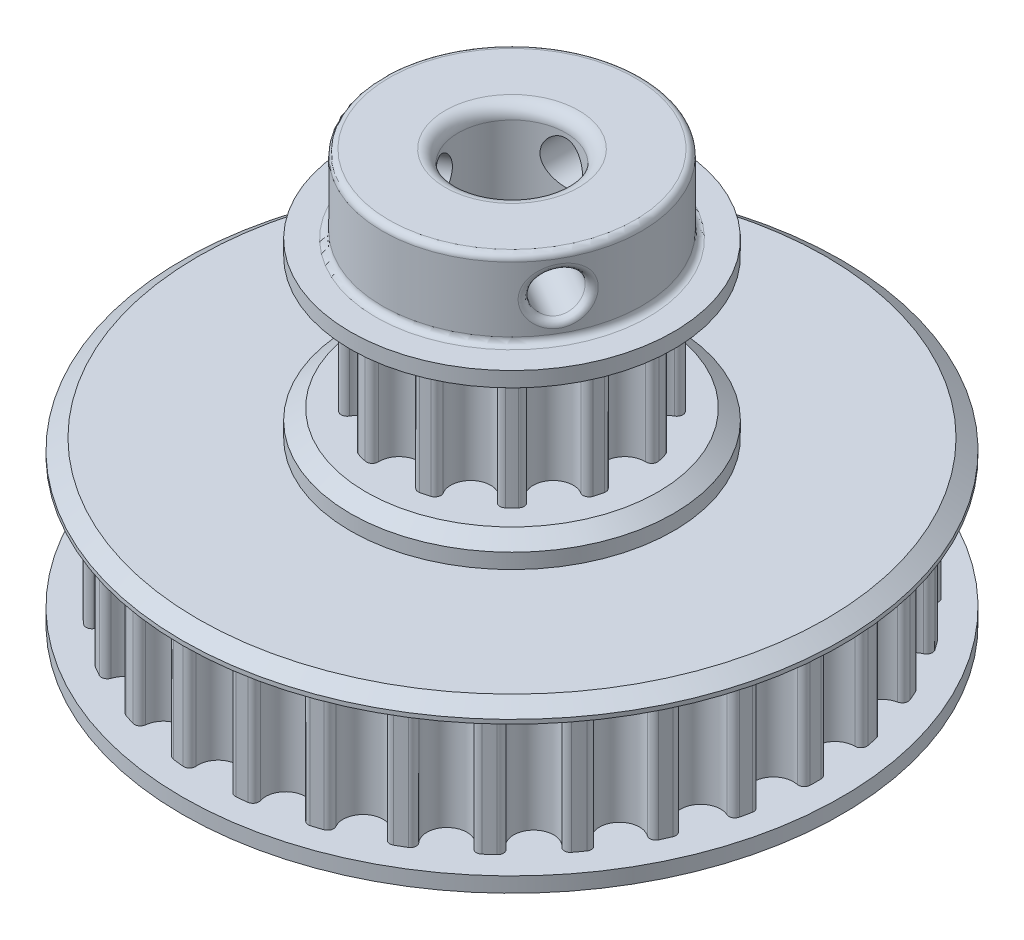
from build123d import *

# Parameters (mm, degrees)
BOSS_EXTRU_1_DEPTH           = 9.3
R_P_TITION_CIRCULAIRE1_COUNT = 12
ESQUISSE2_R                  = 12.462209394
BOSS_EXTRU_2_DEPTH           = 2
ESQUISSE4_R                  = 10
BOSS_EXTRU_3_DEPTH           = 6
ESQUISSE5_R                  = 1.65
ENL_V_MAT_EXTRU_2_DEPTH      = 13.462209394
R_P_TITION_CIRCULAIRE2_COUNT = 3
ESQUISSE10_R                 = 12.462209394
BOSS_EXTRU_6_DEPTH           = 2
BOSS_EXTRU_4_DEPTH           = 9.3
R_P_TITION_CIRCULAIRE3_COUNT = 30
ESQUISSE9_R                  = 25.4290252
BOSS_EXTRU_5_DEPTH           = 2
CHANFREIN1_SIZE              = 1.2
CHANFREIN1_SIZE2             = 0.840249046
CHANFREIN1_PART_2_SIZE       = 1.2
CHANFREIN1_PART_2_SIZE2      = 0.840249046
CHANFREIN1_PART_3_SIZE       = 1.2
CHANFREIN1_PART_3_SIZE2      = 0.840249046
CHANFREIN1_PART_4_SIZE       = 1.2
CHANFREIN1_PART_4_SIZE2      = 0.840249046
CHANFREIN1_PART_5_SIZE       = 1.2
CHANFREIN1_PART_5_SIZE2      = 0.840249046
ESQUISSE3_R                  = 4.15
ENL_V_MAT_EXTRU_3_DEPTH      = 33.6
CONG_2_R                     = 0.5
CONG_3_R                     = 1


with BuildPart() as part:
    # Esquisse1 → Boss.-Extru.1 (new body)
    with BuildSketch(Plane(origin=(0, 0, 0), x_dir=(1, 0, 0), z_dir=(0, 1, 0))):
        with BuildLine():
            Line((0, 0), (-2.449, 9.139792428))
            ThreePointArc((-2.449, 9.139792428), (-2.275575871, 9.184506578), (-2.101336519, 9.225930384))
            ThreePointArc((-2.101336519, 9.225930384), (-1.70739936, 9.132025425), (-1.541940008, 8.762393406))
            ThreePointArc((-1.541940008, 8.762393406), (0, 7.162209394), (1.541940008, 8.762393406))
            ThreePointArc((1.541940008, 8.762393406), (1.70739936, 9.132025425), (2.101336519, 9.225930384))
            ThreePointArc((2.101336519, 9.225930384), (2.275575871, 9.184506578), (2.449, 9.139792428))
            Line((2.449, 9.139792428), (0, 0))
        make_face()
    boss_extru_1 = extrude(amount=BOSS_EXTRU_1_DEPTH)

    # Répétition circulaire1: Boss.-Extru.1 ×12 about axis
    r_p_tition_circulaire1_axis = Axis((0, 0, 0), (0, 1, 0))
    for i in range(1, R_P_TITION_CIRCULAIRE1_COUNT):
        add(boss_extru_1.rotate(r_p_tition_circulaire1_axis, i * 360 / R_P_TITION_CIRCULAIRE1_COUNT))

    # Esquisse2 → Boss.-Extru.2 (add)
    with BuildSketch(Plane(origin=(0, 9.3, 0), x_dir=(1, 0, 0), z_dir=(0, 1, 0))):
        Circle(ESQUISSE2_R)
    boss_extru_2 = extrude(amount=BOSS_EXTRU_2_DEPTH)

    # Symétrie1: Boss.-Extru.2 across plane
    add(boss_extru_2.mirror(Plane(origin=(0, 4.65, 0), x_dir=(0, 0, 1), z_dir=(0, -1, 0))))

    # Esquisse4 → Boss.-Extru.3 (add)
    with BuildSketch(Plane(origin=(0, 11.3, 0), x_dir=(1, 0, 0), z_dir=(0, 1, 0))):
        Circle(ESQUISSE4_R)
    extrude(amount=BOSS_EXTRU_3_DEPTH)

    # Esquisse5 → Enlèv. mat.-Extru.2 (cut, through all)
    with BuildSketch(Plane.XY):
        with Locations((0, 14.3)):
            Circle(ESQUISSE5_R)
    enl_v_mat_extru_2 = extrude(amount=-ENL_V_MAT_EXTRU_2_DEPTH, mode=Mode.SUBTRACT)

    # Répétition circulaire2: Enlèv. mat.-Extru.2 ×3 about axis
    r_p_tition_circulaire2_axis = Axis((0, 17.3, 0), (0, -1, 0))
    for i in range(1, R_P_TITION_CIRCULAIRE2_COUNT):
        add(enl_v_mat_extru_2.rotate(r_p_tition_circulaire2_axis, i * 360 / R_P_TITION_CIRCULAIRE2_COUNT), mode=Mode.SUBTRACT)

    # Esquisse10 → Boss.-Extru.6 (add)
    with BuildSketch(Plane.XZ.offset(2)):
        Circle(ESQUISSE10_R)
    extrude(amount=BOSS_EXTRU_6_DEPTH)

    # Esquisse7 → Boss.-Extru.4 (add)
    with BuildSketch(Plane(origin=(0, -4, 0), x_dir=(1, 0, 0), z_dir=(0, 1, 0))):
        with BuildLine():
            Line((0, 0), (-2.449, 23.300678548))
            ThreePointArc((-2.449, 23.300678548), (-2.23925905, 23.321769674), (-2.029336827, 23.340972856))
            ThreePointArc((-2.029336827, 23.340972856), (-1.662628217, 23.205334027), (-1.534260602, 22.83601729))
            ThreePointArc((-1.534260602, 22.83601729), (0, 21.1290252), (1.534260602, 22.83601729))
            ThreePointArc((1.534260602, 22.83601729), (1.662628217, 23.205334027), (2.029336827, 23.340972856))
            ThreePointArc((2.029336827, 23.340972856), (2.23925905, 23.321769674), (2.449, 23.300678548))
            Line((2.449, 23.300678548), (0, 0))
        make_face()
    boss_extru_4 = extrude(amount=-BOSS_EXTRU_4_DEPTH)

    # Répétition circulaire3: Boss.-Extru.4 ×30 about axis
    r_p_tition_circulaire3_axis = Axis((0, 0, 0), (0, 1, 0))
    for i in range(1, R_P_TITION_CIRCULAIRE3_COUNT):
        add(boss_extru_4.rotate(r_p_tition_circulaire3_axis, i * 360 / R_P_TITION_CIRCULAIRE3_COUNT))

    # Esquisse9 → Boss.-Extru.5 (add)
    with BuildSketch(Plane(origin=(0, -4, 0), x_dir=(1, 0, 0), z_dir=(0, 1, 0))):
        Circle(ESQUISSE9_R)
    boss_extru_5 = extrude(amount=BOSS_EXTRU_5_DEPTH)

    # Symétrie2: Boss.-Extru.5 across plane
    add(boss_extru_5.mirror(Plane.ZX.offset(-8.65)))

    # Chanfrein1
    chanfrein1_edges = [part.edges().sort_by_distance(p)[0] for p in [
        (-12.462209394, 9.3, 0),
    ]]
    chanfrein1_side = [part.faces().sort_by_distance(p)[0] for p in [
        (-12.109724883, 9.3, 0),
    ]]
    chamfer(chanfrein1_edges, length=CHANFREIN1_SIZE, length2=CHANFREIN1_SIZE2, reference=chanfrein1_side[0])

    # Chanfrein1 part 2
    chanfrein1_part_2_edges = [part.edges().sort_by_distance(p)[0] for p in [
        (-12.462209394, 0, 0),
    ]]
    chanfrein1_part_2_side = [part.faces().sort_by_distance(p)[0] for p in [
        (-12.109724883, 0, 0),
    ]]
    chamfer(chanfrein1_part_2_edges, length=CHANFREIN1_PART_2_SIZE, length2=CHANFREIN1_PART_2_SIZE2, reference=chanfrein1_part_2_side[0])

    # Chanfrein1 part 3
    chanfrein1_part_3_edges = [part.edges().sort_by_distance(p)[0] for p in [
        (-25.4290252, -4, 0),
    ]]
    chanfrein1_part_3_side = [part.faces().sort_by_distance(p)[0] for p in [
        (-24.709783754, -4, 0),
    ]]
    chamfer(chanfrein1_part_3_edges, length=CHANFREIN1_PART_3_SIZE, length2=CHANFREIN1_PART_3_SIZE2, reference=chanfrein1_part_3_side[0])

    # Chanfrein1 part 4
    chanfrein1_part_4_edges = [part.edges().sort_by_distance(p)[0] for p in [
        (-25.4290252, -2, 0),
    ]]
    chanfrein1_part_4_side = [part.faces().sort_by_distance(p)[0] for p in [
        (-24.709783754, -2, 0),
    ]]
    chamfer(chanfrein1_part_4_edges, length=CHANFREIN1_PART_4_SIZE, length2=CHANFREIN1_PART_4_SIZE2, reference=chanfrein1_part_4_side[0])

    # Chanfrein1 part 5
    chanfrein1_part_5_edges = [part.edges().sort_by_distance(p)[0] for p in [
        (-25.4290252, -15.3, 0),
    ]]
    chanfrein1_part_5_side = [part.faces().sort_by_distance(p)[0] for p in [
        (0, -15.3, 0),
    ]]
    chamfer(chanfrein1_part_5_edges, length=CHANFREIN1_PART_5_SIZE, length2=CHANFREIN1_PART_5_SIZE2, reference=chanfrein1_part_5_side[0])

    # Esquisse3 → Enlèv. mat.-Extru.3 (cut, through all)
    with BuildSketch(Plane(origin=(0, 17.3, 0), x_dir=(1, 0, 0), z_dir=(0, 1, 0))):
        Circle(ESQUISSE3_R)
    extrude(amount=-ENL_V_MAT_EXTRU_3_DEPTH, mode=Mode.SUBTRACT)

    # Congé2
    cong_2_edges = [part.edges().sort_by_distance(p)[0] for p in [
        (-10, 11.3, 0),
        (-10, 17.3, 0),
        (-1.650000023, 14.300000005, -9.862935666),
        (9.366552854, 14.300000005, 3.502525897),
        (-7.716552831, 14.300000005, 6.360409769),
    ]]
    fillet(cong_2_edges, radius=CONG_2_R)

    # Congé3
    cong_3_edges = [part.edges().sort_by_distance(p)[0] for p in [
        (-4.15, -15.3, 0),
        (-4.15, 17.3, 0),
    ]]
    fillet(cong_3_edges, radius=CONG_3_R)


solid = part.part
